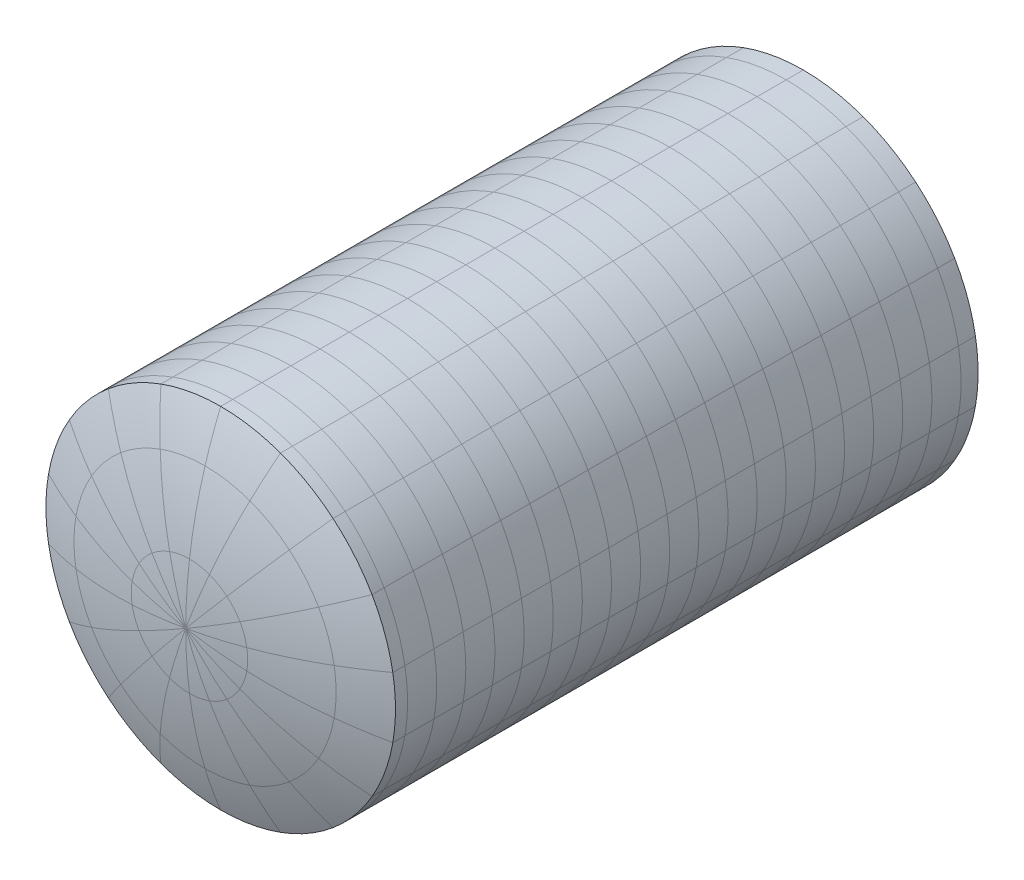
from build123d import *

# Parameters (mm, degrees)
SKETCH2_R           = 6000
BOSS_EXTRUDE1_DEPTH = 20000
DOME1_FACE_RADIUS   = 6000
DOME1_HEIGHT        = 1200
SKETCH3_R           = 5950
CUT_EXTRUDE1_DEPTH  = 19950


with BuildPart() as part:
    # Sketch2 → Boss-Extrude1 (new body)
    with BuildSketch(Plane.XY):
        Circle(SKETCH2_R)
    extrude(amount=BOSS_EXTRUDE1_DEPTH)

    # Dome1: a dome of height H over a round flat face of radius A is a cap of a sphere of radius (A * A + H * H) / (2 * H)
    dome1_r = (DOME1_FACE_RADIUS * DOME1_FACE_RADIUS + DOME1_HEIGHT * DOME1_HEIGHT) / (2 * DOME1_HEIGHT)
    dome1_base = Plane((0, 0, 20000), z_dir=(0, 0, 1))
    with Locations(dome1_base.offset(DOME1_HEIGHT - dome1_r)):
        dome1_ball = Sphere(dome1_r, mode=Mode.PRIVATE)
    add(split(dome1_ball, bisect_by=dome1_base, keep=Keep.TOP, mode=Mode.PRIVATE))

    # Sketch3 → Cut-Extrude1 (cut)
    with BuildSketch(Plane.XY.offset(50)):
        Circle(SKETCH3_R)
    extrude(amount=CUT_EXTRUDE1_DEPTH, mode=Mode.SUBTRACT)


solid = part.part
